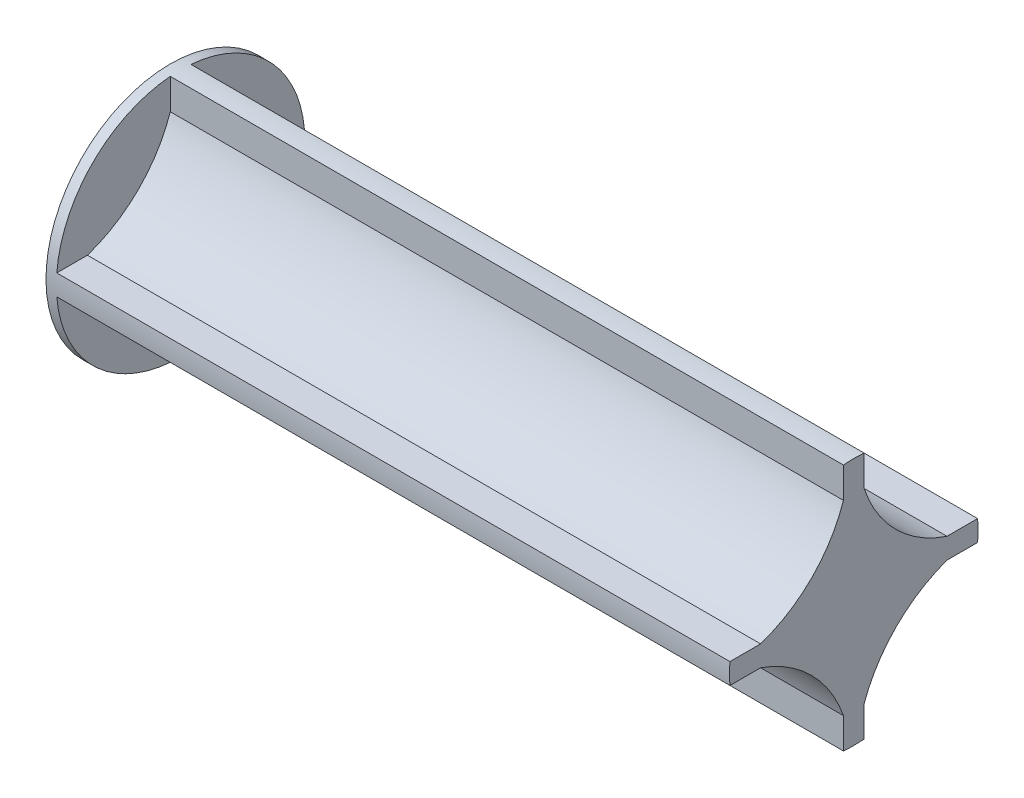
from build123d import *

# Parameters (mm, degrees)
CROQUIS1_R              = 12
SALIENTE_EXTRUIR1_DEPTH = 66
CROQUIS2_R              = 5.25
CORTAR_EXTRUIR1_DEPTH   = 50
CORTAR_EXTRUIR3_DEPTH   = 65
REDONDEO1_R             = 1


with BuildPart() as part:
    # Croquis1 → Saliente-Extruir1 (new body)
    with BuildSketch(Plane(origin=(0, 0, 0), x_dir=(0, 0, -1), z_dir=(1, 0, 0))):
        Circle(CROQUIS1_R)
    extrude(amount=SALIENTE_EXTRUIR1_DEPTH)

    # Croquis2 → Cortar-Extruir1 (cut)
    with BuildSketch(Plane.ZY):
        Circle(CROQUIS2_R)
    extrude(amount=-CORTAR_EXTRUIR1_DEPTH, mode=Mode.SUBTRACT)

    # Croquis3 → Cortar-Extruir3 (cut)
    with BuildSketch(Plane(origin=(66, 0, 0), x_dir=(0, 0, -1), z_dir=(1, 0, 0))):
        with BuildLine():
            ThreePointArc((-1, 11.958260743), (-8.485281374, 8.485281374), (-11.958260743, 1))
            Line((-11.958260743, 1), (-9, 1))
            ThreePointArc((-9, 1), (-4.056739766, 4.056739766), (-1, 9))
            Line((-1, 9), (-1, 11.958260743))
        make_face()
        with BuildLine():
            Line((9, 1), (11.958260743, 1))
            ThreePointArc((11.958260743, 1), (8.485281374, 8.485281374), (1, 11.958260743))
            Line((1, 11.958260743), (1, 9))
            ThreePointArc((1, 9), (4.049951004, 4.049951004), (9, 1))
        make_face()
        with BuildLine():
            ThreePointArc((9, -1), (4.106809031, -4.106809031), (1, -9))
            Line((1, -9), (1, -11.958260743))
            ThreePointArc((1, -11.958260743), (8.485281374, -8.485281374), (11.958260743, -1))
            Line((11.958260743, -1), (9, -1))
        make_face()
        with BuildLine():
            ThreePointArc((-11.958260743, -1), (-8.485281374, -8.485281374), (-1, -11.958260743))
            Line((-1, -11.958260743), (-1, -9))
            ThreePointArc((-1, -9), (-4.086933884, -4.086933884), (-9, -1))
            Line((-9, -1), (-11.958260743, -1))
        make_face()
    extrude(amount=-CORTAR_EXTRUIR3_DEPTH, mode=Mode.SUBTRACT)

    # Redondeo1
    redondeo1_edges = [part.edges().sort_by_distance(p)[0] for p in [
        (0, 0, -5.25),
    ]]
    fillet(redondeo1_edges, radius=REDONDEO1_R)

    # Croquis8 → Cortar-Revolución1 (revolve, cut)
    with BuildSketch(Plane.XY):
        with BuildLine():
            Line((50, 0), (62.972700569, 0))
            ThreePointArc((62.972700569, 0), (56.963621034, 3.875725549), (50, 5.5))
            Line((50, 5.5), (50, 0))
        make_face()
    revolve(axis=Axis((50, 0, 0), (1, 0, 0)), mode=Mode.SUBTRACT)


solid = part.part
